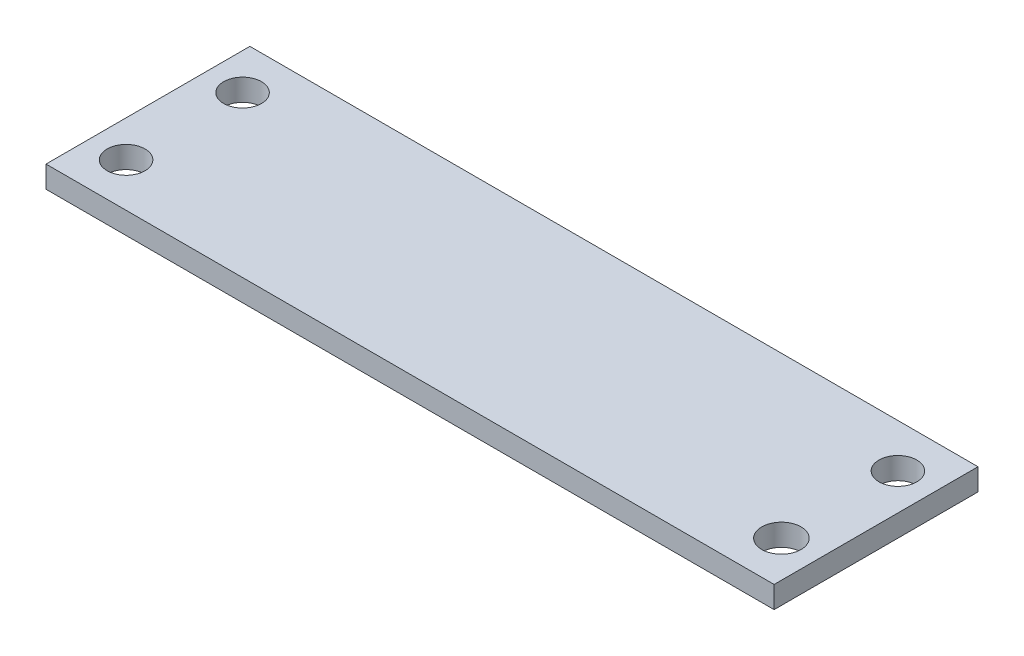
from build123d import *

# Parameters (mm, degrees)
SKETCH_1_R      = 1.35
SKETCH_1_R_2    = 1.3
EXTRUDE_1_DEPTH = 1.5


with BuildPart() as part:
    # 草图1 → 凸台-拉伸1 (new body)
    with BuildSketch(Plane(origin=(0, 0, 0), x_dir=(1, 0, 0), z_dir=(0, 1, 0))):
        Polygon((0, 11), (25, 11), (25, -3), (-25, -3), (-25, 11), align=None)
        with Locations((22.5, 0)):
            Circle(SKETCH_1_R, mode=Mode.SUBTRACT)
        with Locations((-22.5, 0)):
            Circle(SKETCH_1_R_2, mode=Mode.SUBTRACT)
        with Locations((-22.5, 8)):
            Circle(SKETCH_1_R_2, mode=Mode.SUBTRACT)
        with Locations((22.5, 8)):
            Circle(SKETCH_1_R_2, mode=Mode.SUBTRACT)
    extrude(amount=EXTRUDE_1_DEPTH)


solid = part.part
